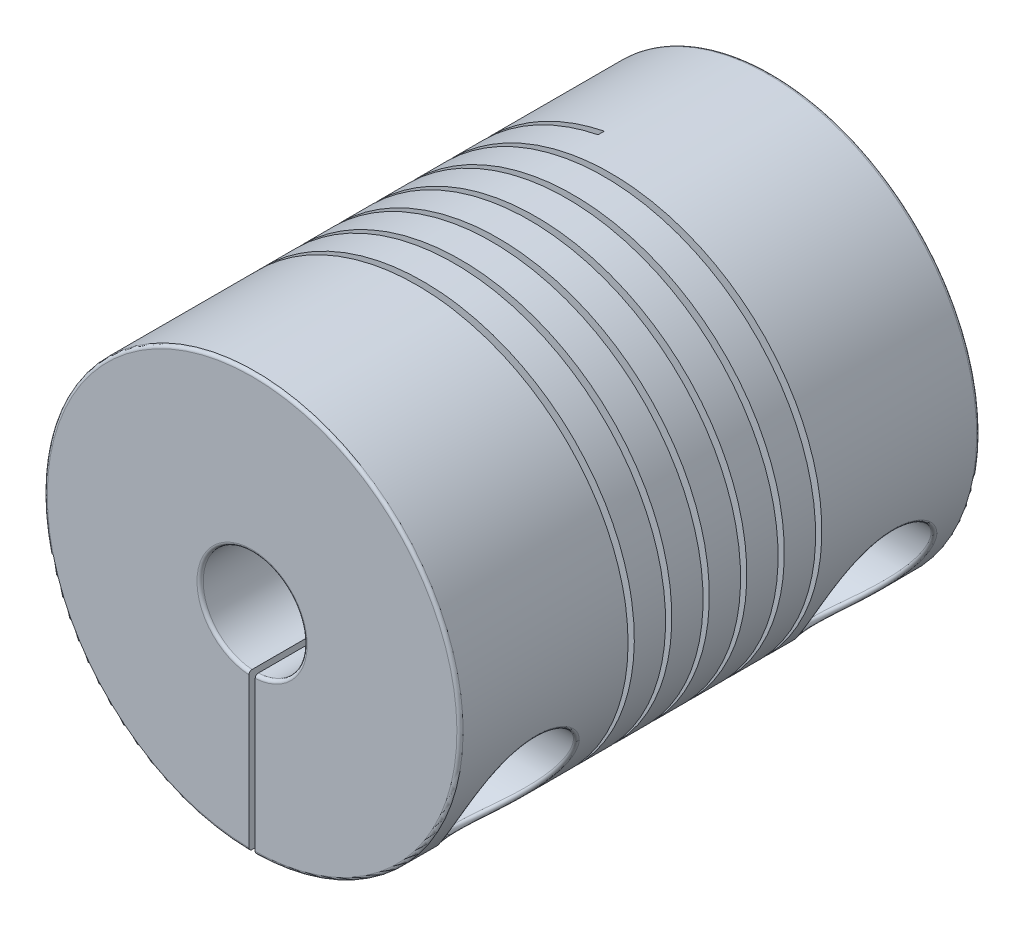
from build123d import *

# Parameters (mm, degrees)
SKETCH1_R              = 10
BOSS_EXTRUDE1_DEPTH    = 25
SKETCH2_R              = 2.5
CUT_EXTRUDE1_DEPTH     = 12.5
SKETCH3_R              = 2.5
CUT_EXTRUDE2_DEPTH     = 12.5
CUT_SWEEP2_PITCH       = 1.804
CUT_SWEEP2_HEIGHT      = 11.0044
CUT_SWEEP2_RADIUS      = 11.25
CUT_SWEEP2_START_ANGLE = 45
SKETCH5_W              = 0.3
SKETCH5_H              = 11.41
SKETCH6_W              = 0.3
SKETCH6_H              = 25
CUT_EXTRUDE3_DEPTH     = 12.5
SKETCH8_R              = 1.5
CUT_EXTRUDE4_DEPTH     = 34.541019845
SKETCH10_R             = 2.72
CUT_EXTRUDE6_DEPTH     = 6
FILLET1_R              = 0.15
FILLET2_R              = 0.15


with BuildPart() as part:
    # Sketch1 → Boss-Extrude1 (new body)
    with BuildSketch(Plane.XY):
        Circle(SKETCH1_R)
    extrude(amount=-BOSS_EXTRUDE1_DEPTH)

    # Sketch2 → Cut-Extrude1 (cut)
    with BuildSketch(Plane.XY):
        Circle(SKETCH2_R)
    extrude(amount=-CUT_EXTRUDE1_DEPTH, mode=Mode.SUBTRACT)

    # Sketch3 → Cut-Extrude2 (cut)
    with BuildSketch(Plane(origin=(0, 0, -25), x_dir=(-1, 0, 0), z_dir=(0, 0, -1))):
        with Locations(Location((0, 0, 0), (0, 0, 180))):
            Circle(SKETCH3_R)
    extrude(amount=-CUT_EXTRUDE2_DEPTH, mode=Mode.SUBTRACT)

    # Cut-Sweep2: sweep along a helix
    with BuildLine() as cut_sweep2_path:
        add(Helix(CUT_SWEEP2_PITCH, CUT_SWEEP2_HEIGHT, CUT_SWEEP2_RADIUS, center=(0, 0, -7.25), direction=(0, 0, -1), mode=Mode.PRIVATE).rotate(Axis((0, 0, -7.25), (0, 0, -1)), CUT_SWEEP2_START_ANGLE))
    # Sketch5 → Cut-Sweep2 (sweep, cut)
    with BuildSketch(Plane(origin=(-1.759887732, 0, 0), x_dir=(0, 0, -1), z_dir=(1, 0, 0))):
        with Locations((14.942267014, 5.705)):
            Rectangle(SKETCH5_W, SKETCH5_H)
    sweep(path=cut_sweep2_path.line, is_frenet=True, mode=Mode.SUBTRACT)

    # Sketch6 → Cut-Extrude3 (cut)
    with BuildSketch(Plane(origin=(0, 0, 0), x_dir=(1, 0, 0), z_dir=(0, 1, 0))):
        with Locations((0, 12.5)):
            Rectangle(SKETCH6_W, SKETCH6_H)
    extrude(amount=-CUT_EXTRUDE3_DEPTH, mode=Mode.SUBTRACT)


with BuildPart() as cut_extrude3_piece_1:
    # of the separate pieces the step leaves, piece 1, a body of its own (cut_extrude3_pieces)
    add(part.part.solids().sort_by_distance((0.15, -9.998874936, -8.524752292))[0])


with BuildPart() as cut_extrude3_piece_2:
    # of the separate pieces the step leaves, piece 2, a body of its own (cut_extrude3_pieces)
    add(part.part.solids().sort_by_distance((-0.15, -9.998874936, -17.553367148))[0])


with BuildPart() as cut_extrude3_piece_3:
    # of the separate pieces the step leaves, piece 3, a body of its own (cut_extrude3_pieces)
    add(part.part.solids().sort_by_distance((-0.15, -9.998874936, -10.337367843))[0])


with BuildPart() as cut_extrude3_piece_4:
    # of the separate pieces the step leaves, piece 4, a body of its own (cut_extrude3_pieces)
    add(part.part.solids().sort_by_distance((-0.15, -9.998874941, -15.749365484))[0])


with BuildPart() as cut_extrude3_piece_5:
    # of the separate pieces the step leaves, piece 5, a body of its own (cut_extrude3_pieces)
    add(part.part.solids().sort_by_distance((-0.15, -9.998874942, -13.945366717))[0])


with BuildPart() as cut_extrude3_piece_6:
    # of the separate pieces the step leaves, piece 6, a body of its own (cut_extrude3_pieces)
    add(part.part.solids().sort_by_distance((-0.15, -9.998874937, -12.141367477))[0])


with BuildPart() as cut_extrude4_tool:
    # Sketch8 → Cut-Extrude4 (new, through all)
    with BuildSketch(Plane(origin=(10, 0, 0), x_dir=(0, 0, -1), z_dir=(1, 0, 0))):
        with Locations((3.9, -5)):
            Circle(SKETCH8_R)
        with Locations((21.1, -5)):
            Circle(SKETCH8_R)
    extrude(amount=-CUT_EXTRUDE4_DEPTH)


with BuildPart() as cut_extrude3_piece_1_1:
    add(cut_extrude3_piece_1.part)

    # Cut-Extrude4: cut by cut_extrude4_tool
    add(cut_extrude4_tool.part, mode=Mode.SUBTRACT)


with BuildPart() as cut_extrude3_piece_2_1:
    add(cut_extrude3_piece_2.part)

    # Cut-Extrude4: cut by cut_extrude4_tool
    add(cut_extrude4_tool.part, mode=Mode.SUBTRACT)


with BuildPart() as cut_extrude6_tool:
    # Sketch10 → Cut-Extrude6 (new body)
    with BuildSketch(Plane(origin=(10, 0, 0), x_dir=(0, 0, -1), z_dir=(1, 0, 0))):
        with Locations((3.9, -5)):
            Circle(SKETCH10_R)
        with Locations((21.1, -5)):
            Circle(SKETCH10_R)
    extrude(amount=-CUT_EXTRUDE6_DEPTH)


with BuildPart() as cut_extrude3_piece_1_2:
    add(cut_extrude3_piece_1_1.part)

    # Cut-Extrude6: cut by cut_extrude6_tool
    add(cut_extrude6_tool.part, mode=Mode.SUBTRACT)

    # Fillet1
    fillet1_edges = [cut_extrude3_piece_1_2.edges().sort_by_distance(p)[0] for p in [
        (8.423949183, -5.38860651, -1.207903228),
        (0, 2.5, 0),
        (0, 10, 0),
    ]]
    fillet(fillet1_edges, radius=FILLET1_R)


with BuildPart() as cut_extrude3_piece_2_2:
    add(cut_extrude3_piece_2_1.part)

    # Cut-Extrude6: cut by cut_extrude6_tool
    add(cut_extrude6_tool.part, mode=Mode.SUBTRACT)

    # Fillet2
    fillet2_edges = [cut_extrude3_piece_2_2.edges().sort_by_distance(p)[0] for p in [
        (0, 2.5, -25),
        (8.423949183, -5.38860651, -18.407903228),
        (0, 10, -25),
    ]]
    fillet(fillet2_edges, radius=FILLET2_R)


solid = Compound([cut_extrude3_piece_3.part, cut_extrude3_piece_4.part, cut_extrude3_piece_5.part, cut_extrude3_piece_6.part, cut_extrude3_piece_1_2.part, cut_extrude3_piece_2_2.part])
